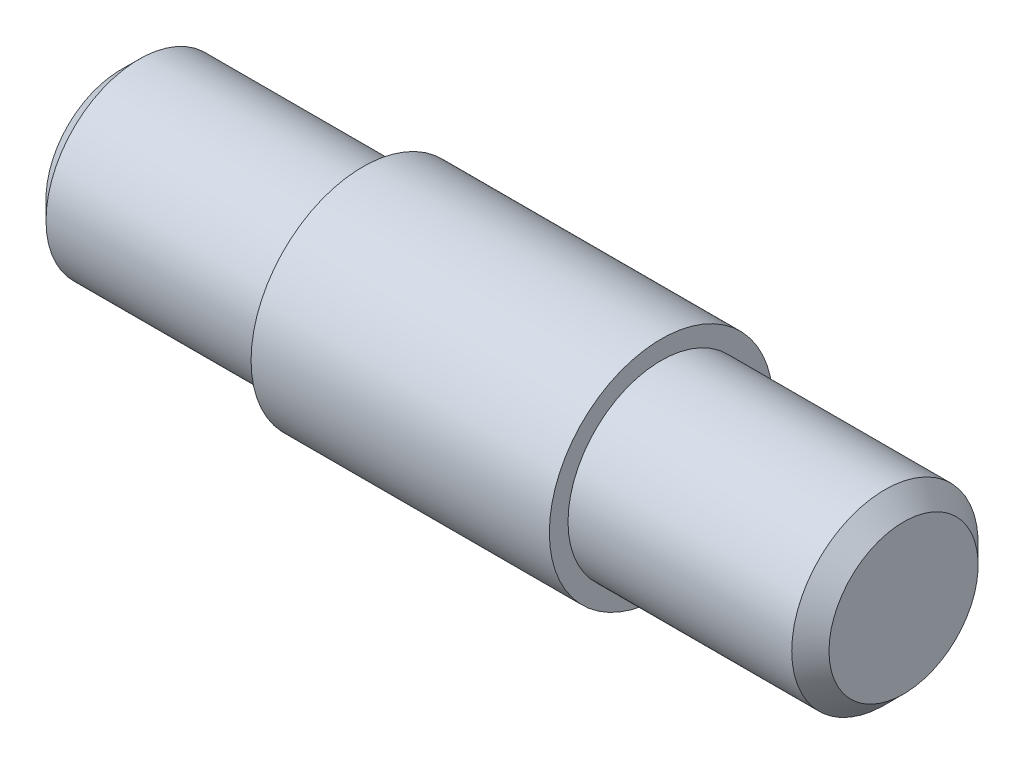
from build123d import *

# Parameters (mm, degrees)
CHANFREIN1_SIZE = 0.5


with BuildPart() as part:
    # Esquisse1 → Révolution1 (revolve)
    with BuildSketch(Plane.XY, mode=Mode.PRIVATE) as r_volution1_sk:
        Polygon((0, 0), (0, 2.5), (6.5, 2.5), (6.5, 3), (14.5, 3), (14.5, 2.5), (21, 2.5), (21, 0), align=None)
    revolve(r_volution1_sk.sketch.rotate(Axis((-54.824636662, 0, 0), (1, 0, 0)), 90), axis=Axis((-54.824636662, 0, 0), (1, 0, 0)))  # turned: the seam where the file's is

    # Chanfrein1
    chanfrein1_edges = [part.edges().sort_by_distance(p)[0] for p in [
        (21, 0, -2.5),
        (0, 0, -2.5),
    ]]
    chamfer(chanfrein1_edges, length=CHANFREIN1_SIZE)


solid = part.part
